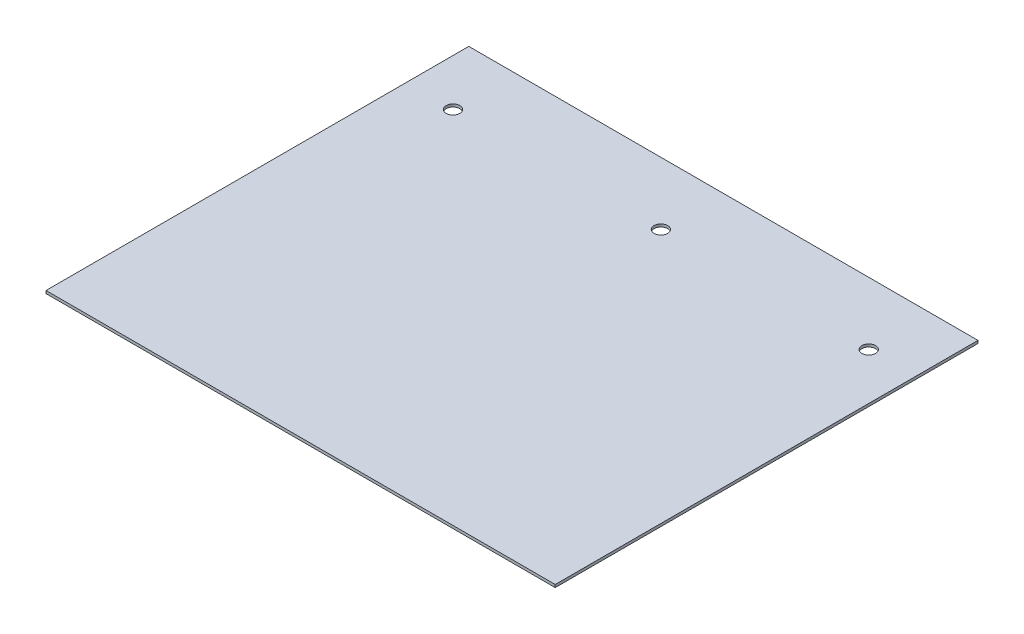
from build123d import *

# Parameters (mm, degrees)
SKETCH1_W               = 186.69
SKETCH1_H               = 199.9996
SKETCH1_R               = 2.5
BOSS_EXTRUDE1_DEPTH     = 1
SKETCH2_W               = 186.69
SKETCH2_H               = 45
CUT_EXTRUDE1_DEPTH      = 1
CUT_EXTRUDE1_DEPTH_BACK = 2


with BuildPart() as part:
    # Sketch1 → Boss-Extrude1 (new body)
    with BuildSketch(Plane(origin=(0, 0, 0), x_dir=(1, 0, 0), z_dir=(0, 1, 0))):
        with Locations((93.345, -99.9998)):
            Rectangle(SKETCH1_W, SKETCH1_H)
        with Locations((169.545, -67.9196)):
            Circle(SKETCH1_R, mode=Mode.SUBTRACT)
        with Locations((17.145, -67.9196)):
            Circle(SKETCH1_R, mode=Mode.SUBTRACT)
        with Locations((93.345, -67.9196)):
            Circle(SKETCH1_R, mode=Mode.SUBTRACT)
    extrude(amount=-BOSS_EXTRUDE1_DEPTH)

    # Sketch2 → Cut-Extrude1 (cut, two sides)
    with BuildSketch(Plane(origin=(0, 0, 0), x_dir=(1, 0, 0), z_dir=(0, 1, 0))) as cut_extrude1_sk:
        with Locations((93.345, -22.5)):
            Rectangle(SKETCH2_W, SKETCH2_H)
    extrude(amount=CUT_EXTRUDE1_DEPTH, mode=Mode.SUBTRACT)
    extrude(cut_extrude1_sk.sketch, amount=-CUT_EXTRUDE1_DEPTH_BACK, mode=Mode.SUBTRACT)


solid = part.part
